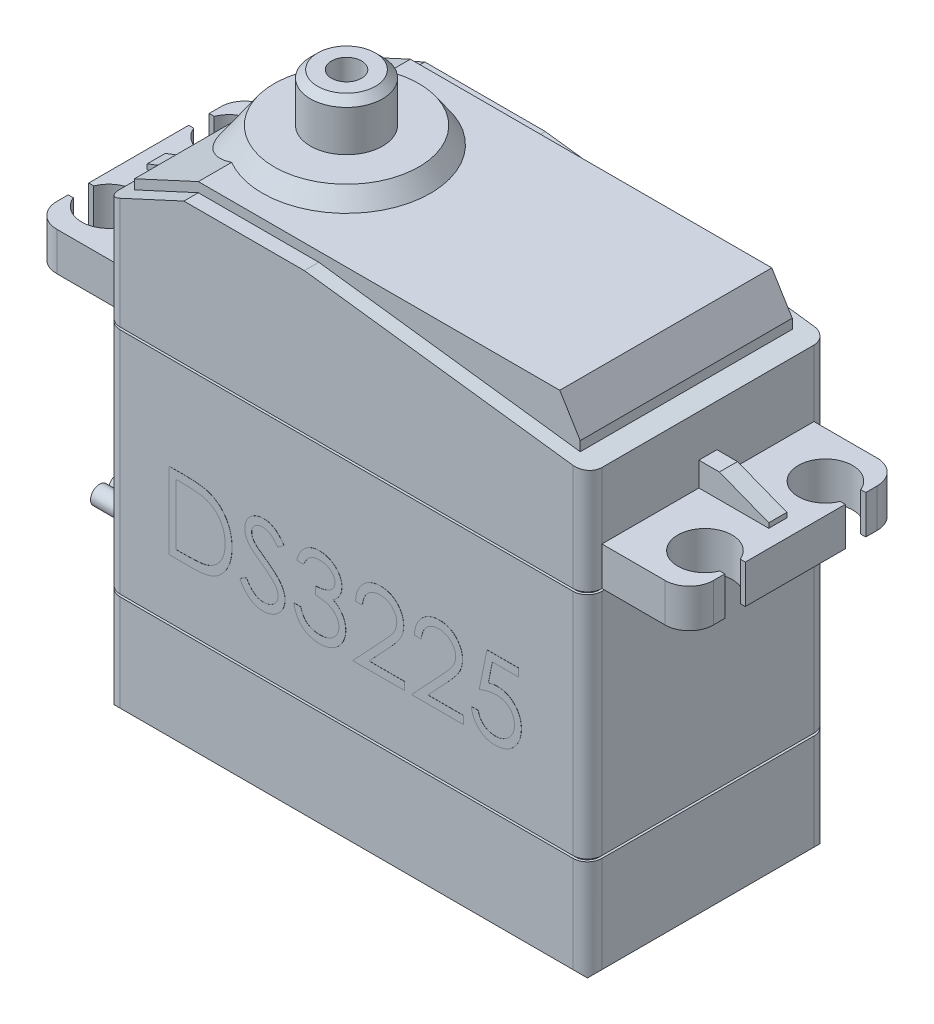
from build123d import *

# Parameters (mm, degrees)
SKETCH1_W              = 40
SKETCH1_H              = 20
BOSS_EXTRUDE1_DEPTH    = 41.5
CHAMFER1_SIZE          = 1.6
FILLET2_R              = 1.2
BOSS_EXTRUDE3_DEPTH    = 3.2
CUT_EXTRUDE1_REACH     = 55.524
BOSS_EXTRUDE4_DEPTH    = 8.8
BOSS_EXTRUDE5_REACH    = 53.797
SKETCH6_R              = 6
BOSS_EXTRUDE5_DRAFT    = 35
SKETCH7_R              = 3
SKETCH7_R_2            = 1.25
BOSS_EXTRUDE6_DEPTH    = 4
CHAMFER2_SIZE          = 0.6
BOSS_EXTRUDE7_DEPTH    = 0.75
CUT_EXTRUDE2_DEPTH     = 0.2
LPATTERN1_COUNT        = 2
LPATTERN1_PITCH        = 19.2
BOSS_EXTRUDE8_DEPTH    = 0.6
SKETCH11_W             = 6.4
SKETCH11_H             = 3.4
BOSS_EXTRUDE9_DEPTH    = 4.2
BOSS_EXTRUDE9_TAPER    = 5
FILLET3_R              = 0.5
SKETCH12_R             = 0.75
BOSS_EXTRUDE11_DEPTH   = 4.2
BOSS_EXTRUDE11_2_DEPTH = 4.2
BOSS_EXTRUDE11_3_DEPTH = 4.2
BOSS_EXTRUDE12_DEPTH   = 0.01


with BuildPart() as part:
    # Sketch1 → Boss-Extrude1 (new body)
    with BuildSketch(Plane(origin=(0, 0, 0), x_dir=(1, 0, 0), z_dir=(0, 1, 0))):
        Rectangle(SKETCH1_W, SKETCH1_H)
    extrude(amount=BOSS_EXTRUDE1_DEPTH)

    # Chamfer1
    chamfer1_edges = [part.edges().sort_by_distance(p)[0] for p in [
        (0, 0, 10),
        (-20, 0, 0),
        (0, 0, -10),
        (20, 0, 0),
    ]]
    chamfer(chamfer1_edges, length=CHAMFER1_SIZE)

    # Fillet2
    fillet2_edges = [part.edges().sort_by_distance(p)[0] for p in [
        (20, 21.55, 10),
        (-20, 21.55, 10),
        (-20, 21.55, -10),
        (20, 21.55, -10),
    ]]
    fillet(fillet2_edges, radius=FILLET2_R)

    # Sketch3 → Boss-Extrude3 (add)
    with BuildSketch(Plane(origin=(0, 29, 0), x_dir=(-1, 0, 0), z_dir=(0, -1, 0))):
        with BuildLine():
            Line((25.25, 8.8), (20, 8.8))
            Line((20, 8.8), (20, 5.85))
            Line((20, 5.85), (22.666733334, 5.85))
            ThreePointArc((22.666733334, 5.85), (24.75, 7.25), (26.833266666, 5.85))
            Line((26.833266666, 5.85), (27.25, 5.85))
            Line((27.25, 5.85), (27.25, 6.8))
            ThreePointArc((27.25, 6.8), (26.664213562, 8.214213562), (25.25, 8.8))
        make_face()
        with BuildLine():
            Line((22.666733334, 4.15), (20, 4.15))
            Line((20, 4.15), (20, -4.15))
            Line((20, -4.15), (22.666733334, -4.15))
            ThreePointArc((22.666733334, -4.15), (24.75, -2.75), (26.833266666, -4.15))
            Line((26.833266666, -4.15), (27.25, -4.15))
            Line((27.25, -4.15), (27.25, 4.15))
            Line((27.25, 4.15), (26.833266666, 4.15))
            ThreePointArc((26.833266666, 4.15), (24.75, 2.75), (22.666733334, 4.15))
        make_face()
        with BuildLine():
            Line((22.666733334, -5.85), (20, -5.85))
            Line((20, -5.85), (20, -8.8))
            Line((20, -8.8), (25.25, -8.8))
            ThreePointArc((25.25, -8.8), (26.664213562, -8.214213562), (27.25, -6.8))
            Line((27.25, -6.8), (27.25, -5.85))
            Line((27.25, -5.85), (26.833266666, -5.85))
            ThreePointArc((26.833266666, -5.85), (24.75, -7.25), (22.666733334, -5.85))
        make_face()
        with BuildLine():
            Line((22.666733334, -4.15), (20, -4.15))
            Line((20, -4.15), (20, -5.85))
            Line((20, -5.85), (22.666733334, -5.85))
            ThreePointArc((22.666733334, -5.85), (22.5, -5), (22.666733334, -4.15))
        make_face()
        with BuildLine():
            Line((22.666733334, 5.85), (20, 5.85))
            Line((20, 5.85), (20, 4.15))
            Line((20, 4.15), (22.666733334, 4.15))
            ThreePointArc((22.666733334, 4.15), (22.5, 5), (22.666733334, 5.85))
        make_face()
        with BuildLine():
            Line((-20, 5.85), (-20, 8.8))
            Line((-20, 8.8), (-25.25, 8.8))
            ThreePointArc((-25.25, 8.8), (-26.664213562, 8.214213562), (-27.25, 6.8))
            Line((-27.25, 6.8), (-27.25, 5.85))
            Line((-27.25, 5.85), (-26.833266666, 5.85))
            ThreePointArc((-26.833266666, 5.85), (-24.75, 7.25), (-22.666733334, 5.85))
            Line((-22.666733334, 5.85), (-20, 5.85))
        make_face()
        with BuildLine():
            Line((-20, 4.15), (-20, 5.85))
            Line((-20, 5.85), (-22.666733334, 5.85))
            ThreePointArc((-22.666733334, 5.85), (-22.542076768, 5.433099297), (-22.5, 5))
            ThreePointArc((-22.5, 5), (-22.542076768, 4.566900703), (-22.666733334, 4.15))
            Line((-22.666733334, 4.15), (-20, 4.15))
        make_face()
        with BuildLine():
            Line((-20, -4.15), (-20, 4.15))
            Line((-20, 4.15), (-22.666733334, 4.15))
            ThreePointArc((-22.666733334, 4.15), (-24.75, 2.75), (-26.833266666, 4.15))
            Line((-26.833266666, 4.15), (-27.25, 4.15))
            Line((-27.25, 4.15), (-27.25, -4.15))
            Line((-27.25, -4.15), (-26.833266666, -4.15))
            ThreePointArc((-26.833266666, -4.15), (-24.75, -2.75), (-22.666733334, -4.15))
            Line((-22.666733334, -4.15), (-20, -4.15))
        make_face()
        with BuildLine():
            Line((-20, -5.85), (-20, -4.15))
            Line((-20, -4.15), (-22.666733334, -4.15))
            ThreePointArc((-22.666733334, -4.15), (-22.542076768, -4.566900703), (-22.5, -5))
            ThreePointArc((-22.5, -5), (-22.542076768, -5.433099297), (-22.666733334, -5.85))
            Line((-22.666733334, -5.85), (-20, -5.85))
        make_face()
        with BuildLine():
            Line((-20, -8.8), (-20, -5.85))
            Line((-20, -5.85), (-22.666733334, -5.85))
            ThreePointArc((-22.666733334, -5.85), (-24.75, -7.25), (-26.833266666, -5.85))
            Line((-26.833266666, -5.85), (-27.25, -5.85))
            Line((-27.25, -5.85), (-27.25, -6.8))
            ThreePointArc((-27.25, -6.8), (-26.664213562, -8.214213562), (-25.25, -8.8))
            Line((-25.25, -8.8), (-20, -8.8))
        make_face()
    extrude(amount=-BOSS_EXTRUDE3_DEPTH)

    # Sketch4 → Cut-Extrude1 (cut, up to next)
    with BuildSketch(Plane.XY.offset(10), mode=Mode.PRIVATE) as cut_extrude1_sk1:
        Polygon((-20, 37.7), (-13.5, 40.7), (-3.5, 40.7), (20, 37.7), (20, 41.5), (-20, 41.5), align=None)
    cut_extrude1_tool1 = extrude(cut_extrude1_sk1.sketch, amount=-CUT_EXTRUDE1_REACH, mode=Mode.PRIVATE) & part.part
    add(cut_extrude1_tool1.solids().sort_by_distance((3.311688, 40.281818, 10))[0], mode=Mode.SUBTRACT)

    # Sketch5 → Boss-Extrude4 (add, symmetric)
    with BuildSketch(Plane.XY):
        Polygon((-13.5, 41.5), (16.5, 41.5), (18.2, 38.729787234), (18.2, 37.929787234), (-3.5, 40.7), (-13.5, 40.7), (-18.8, 38.253846154), (-18.8, 39.053846154), align=None)
    extrude(amount=BOSS_EXTRUDE4_DEPTH, both=True)




with BuildPart() as boss_extrude5_long_prism_1:
    # Sketch6 → Boss-Extrude5 (the long prism of profile 1, to be tilted and cut off)
    with BuildSketch(Plane(origin=(0, 42.9, 0), x_dir=(1, 0, 0), z_dir=(0, 1, 0))):
        with Locations((-10, 0)):
            Circle(SKETCH6_R)
    extrude(amount=-BOSS_EXTRUDE5_REACH)
    boss_extrude5_tool1_sides = [boss_extrude5_long_prism_1.faces().sort_by_distance(p)[0] for p in [
        (-16, 16.0015, 0),
    ]]
    draft(boss_extrude5_tool1_sides, Plane(origin=(0, 42.9, 0), x_dir=(1, 0, 0), z_dir=(0, 1, 0)), BOSS_EXTRUDE5_DRAFT)  # the draft: side faces tilted about the start plane


with BuildPart() as part_1:
    add(part.part)
    boss_extrude5_tool1 = boss_extrude5_long_prism_1.part - part.part
    add(boss_extrude5_tool1.solids().sort_by_distance((-10, 42.9, 0))[0])

    # Sketch7 → Boss-Extrude6 (add)
    with BuildSketch(Plane(origin=(0, 42.9, 0), x_dir=(1, 0, 0), z_dir=(0, 1, 0))):
        with Locations(Location((-10, 0, 0), (0, 0, 270))):
            Circle(SKETCH7_R)
        with Locations(Location((-10, 0, 0), (0, 0, 270))):
            Circle(SKETCH7_R_2, mode=Mode.SUBTRACT)
    extrude(amount=BOSS_EXTRUDE6_DEPTH)

    # Chamfer2
    chamfer2_edges = [part_1.edges().sort_by_distance(p)[0] for p in [
        (-10, 46.9, -3),
    ]]
    chamfer(chamfer2_edges, length=CHAMFER2_SIZE)

    # Sketch8 → Boss-Extrude7 (add, symmetric)
    with BuildSketch(Plane.XY):
        Polygon((-20, 34.2), (-21.7, 34.2), (-25.8, 32.6), (-25.8, 32.2), (-20, 32.2), align=None)
        Polygon((20, 32.2), (20, 34.2), (21.7, 34.2), (25.8, 32.6), (25.8, 32.2), align=None)
    extrude(amount=BOSS_EXTRUDE7_DEPTH, both=True)

    # Sketch9 → Cut-Extrude2 (cut)
    with BuildSketch(Plane(origin=(0, 9.6, 0), x_dir=(-1, 0, 0), z_dir=(0, -1, 0))):
        with BuildLine():
            Line((20, 8.8), (20, -8.8))
            ThreePointArc((20, -8.8), (19.908655439, -9.259220119), (19.648528137, -9.648528137))
            ThreePointArc((19.648528137, -9.648528137), (19.259220119, -9.908655439), (18.8, -10))
            Line((18.8, -10), (-18.8, -10))
            ThreePointArc((-18.8, -10), (-19.259220119, -9.908655439), (-19.648528137, -9.648528137))
            ThreePointArc((-19.648528137, -9.648528137), (-19.908655439, -9.259220119), (-20, -8.8))
            Line((-20, -8.8), (-20, 8.8))
            ThreePointArc((-20, 8.8), (-19.908655439, 9.259220119), (-19.648528137, 9.648528137))
            ThreePointArc((-19.648528137, 9.648528137), (-19.259220119, 9.908655439), (-18.8, 10))
            Line((-18.8, 10), (18.8, 10))
            ThreePointArc((18.8, 10), (19.259220119, 9.908655439), (19.648528137, 9.648528137))
            ThreePointArc((19.648528137, 9.648528137), (19.908655439, 9.259220119), (20, 8.8))
        make_face()
        with BuildLine():
            Line((-18.8, 9.8), (18.8, 9.8))
            ThreePointArc((18.8, 9.8), (19.182683432, 9.723879533), (19.507106781, 9.507106781))
            ThreePointArc((19.507106781, 9.507106781), (19.723879533, 9.182683432), (19.8, 8.8))
            Line((19.8, 8.8), (19.8, -8.8))
            ThreePointArc((19.8, -8.8), (19.723879533, -9.182683432), (19.507106781, -9.507106781))
            ThreePointArc((19.507106781, -9.507106781), (19.182683432, -9.723879533), (18.8, -9.8))
            Line((18.8, -9.8), (-18.8, -9.8))
            ThreePointArc((-18.8, -9.8), (-19.182683432, -9.723879533), (-19.507106781, -9.507106781))
            ThreePointArc((-19.507106781, -9.507106781), (-19.723879533, -9.182683432), (-19.8, -8.8))
            Line((-19.8, -8.8), (-19.8, 8.8))
            ThreePointArc((-19.8, 8.8), (-19.723879533, 9.182683432), (-19.507106781, 9.507106781))
            ThreePointArc((-19.507106781, 9.507106781), (-19.182683432, 9.723879533), (-18.8, 9.8))
        make_face(mode=Mode.SUBTRACT)
    cut_extrude2 = extrude(amount=-CUT_EXTRUDE2_DEPTH, mode=Mode.SUBTRACT)

    # LPattern1: Cut-Extrude2 ×2
    with Locations(*[(0, i * LPATTERN1_PITCH, 0) for i in range(1, LPATTERN1_COUNT)]):
        add(cut_extrude2, mode=Mode.SUBTRACT)

    # Sketch10 → Boss-Extrude8 (add)
    with BuildSketch(Plane.ZY.offset(20)):
        with BuildLine():
            Line((-3, 9.6), (3, 9.6))
            ThreePointArc((3, 9.6), (3.353553391, 9.453553391), (3.5, 9.1))
            Line((3.5, 9.1), (3.5, 6.1))
            ThreePointArc((3.5, 6.1), (3.353553391, 5.746446609), (3, 5.6))
            Line((3, 5.6), (-3, 5.6))
            ThreePointArc((-3, 5.6), (-3.353553391, 5.746446609), (-3.5, 6.1))
            Line((-3.5, 6.1), (-3.5, 9.1))
            ThreePointArc((-3.5, 9.1), (-3.353553391, 9.453553391), (-3, 9.6))
        make_face()
    extrude(amount=BOSS_EXTRUDE8_DEPTH)

    # Sketch11 → Boss-Extrude9 (add)
    with BuildSketch(Plane.ZY.offset(20.6)):
        with Locations((0, 7.6)):
            Rectangle(SKETCH11_W, SKETCH11_H)
    extrude(amount=BOSS_EXTRUDE9_DEPTH, taper=BOSS_EXTRUDE9_TAPER)

    # Fillet3
    fillet3_edges = [part_1.edges().sort_by_distance(p)[0] for p in [
        (-22.7, 6.083726193, 3.016273807),
        (-22.7, 9.116273807, 3.016273807),
        (-22.7, 9.116273807, -3.016273807),
        (-22.7, 6.083726193, -3.016273807),
        (-24.8, 7.6, 2.832547613),
        (-24.8, 8.932547613, 0),
        (-24.8, 7.6, -2.832547613),
        (-24.8, 6.267452387, 0),
    ]]
    fillet(fillet3_edges, radius=FILLET3_R)

    # Sketch13 → Boss-Extrude12 (add)
    with BuildSketch(Plane.XY.offset(10)):
        with BuildLine():
            Line((-14.705907337, 14.680709797), (-14.705907337, 21.030709797))
            Line((-14.705907337, 21.030709797), (-13.423695799, 21.030709797))
            add(Edge.make_bspline(
                [(-13.423695799, 21.030709797), (-13.312173491, 21.029906849), (-13.096712974, 21.028355556), (-12.785358963, 21.018519604), (-12.497279851, 21.001119759), (-12.233423092, 20.975775047), (-11.993064322, 20.944654543), (-11.776876561, 20.905646667), (-11.583741959, 20.859585272), (-11.464961688, 20.820314241), (-11.408791952, 20.801743451)],
                knots=[0, 0, 0, 0, 1.314313732, 2.53924729, 3.670748893, 4.714932338, 5.66265055, 6.526160246, 7.303039223, 8, 8, 8, 8], degree=3))
            add(Edge.make_bspline(
                [(-11.408791952, 20.801743451), (-11.335322925, 20.773747742), (-11.190050905, 20.718391174), (-10.983209411, 20.613967599), (-10.788490539, 20.4956524), (-10.60485009, 20.363289621), (-10.436482876, 20.213131446), (-10.276811407, 20.051556447), (-10.132367551, 19.87268903), (-10.000091071, 19.680238695), (-9.880827803, 19.476472543), (-9.777161045, 19.261778846), (-9.691065943, 19.037247911), (-9.619595374, 18.803504143), (-9.56326823, 18.560033571), (-9.524838154, 18.3065527), (-9.499490787, 18.044063314), (-9.496943436, 17.865946787), (-9.495650927, 17.775571576)],
                knots=[0, 0, 0, 0, 0.984719456, 1.947108742, 2.898477687, 3.838006223, 4.779231079, 5.722358779, 6.681677486, 7.655904652, 8.64651281, 9.637519902, 10.640069247, 11.656948941, 12.698408672, 13.768548281, 14.867775369, 16, 16, 16, 16], degree=3))
            add(Edge.make_bspline(
                [(-9.495650927, 17.775571576), (-9.496792054, 17.697083329), (-9.499040763, 17.54241404), (-9.519232522, 17.314465558), (-9.548580988, 17.093279508), (-9.594018318, 16.879909166), (-9.649177164, 16.672485114), (-9.719869267, 16.473218042), (-9.80085081, 16.280279988), (-9.895284161, 16.09627971), (-9.99895496, 15.92195702), (-10.110210123, 15.757627133), (-10.228930984, 15.605634945), (-10.356249633, 15.465520178), (-10.490520775, 15.337494057), (-10.632623489, 15.220487115), (-10.782924453, 15.116788794), (-10.940750478, 15.022324183), (-11.110705741, 14.939918681), (-11.296009384, 14.870195663), (-11.497451664, 14.812416804), (-11.714538129, 14.764209607), (-11.947643867, 14.725969358), (-12.19699742, 14.700340046), (-12.462215674, 14.683008297), (-12.644332341, 14.68149084), (-12.738068795, 14.680709797)],
                knots=[0, 0, 0, 0, 1.105936401, 2.179363191, 3.223086493, 4.248585256, 5.251745608, 6.245858792, 7.225916811, 8.198733463, 9.158002045, 10.082870192, 10.993790845, 11.873723703, 12.748670949, 13.606408763, 14.465103618, 15.319838547, 16.196477973, 17.123216899, 18.106603292, 19.147568657, 20.255746949, 21.433717677, 22.679120308, 24, 24, 24, 24], degree=3))
            Line((-12.738068795, 14.680709797), (-14.705907337, 14.680709797))
        make_face()
        with BuildLine():
            Line((-14.136035542, 15.331991848), (-13.40715934, 15.331991848))
            add(Edge.make_bspline(
                [(-13.40715934, 15.331991848), (-13.302423582, 15.332441966), (-13.100978362, 15.333307707), (-12.811313138, 15.34090449), (-12.546646233, 15.35331772), (-12.306940066, 15.370689646), (-12.092329979, 15.393674134), (-11.902367462, 15.419300743), (-11.737675207, 15.451227547), (-11.638017515, 15.480167145), (-11.591965029, 15.493540326)],
                knots=[0, 0, 0, 0, 1.375205317, 2.645023457, 3.804390687, 4.853969522, 5.800190428, 6.637939096, 7.370582563, 8, 8, 8, 8], degree=3))
            add(Edge.make_bspline(
                [(-11.591965029, 15.493540326), (-11.534001573, 15.513953867), (-11.419459115, 15.554293373), (-11.25457486, 15.627876558), (-11.100801437, 15.715038599), (-10.955458963, 15.811925582), (-10.820609174, 15.921954757), (-10.694653991, 16.042733551), (-10.577847009, 16.174876643), (-10.47139505, 16.318220022), (-10.376129984, 16.471871508), (-10.293632182, 16.634320535), (-10.221330118, 16.803787176), (-10.164581814, 16.982873793), (-10.12010354, 17.16997937), (-10.088599035, 17.365117071), (-10.068978035, 17.568250454), (-10.066689408, 17.706412165), (-10.065522722, 17.776843611)],
                knots=[0, 0, 0, 0, 0.998632004, 1.973411704, 2.929992603, 3.868527914, 4.809262121, 5.754881198, 6.702106254, 7.672490631, 8.653608572, 9.636854334, 10.631411391, 11.644891563, 12.686317036, 13.754757253, 14.855430412, 16, 16, 16, 16], degree=3))
            add(Edge.make_bspline(
                [(-10.065522722, 17.776843611), (-10.066453972, 17.85110864), (-10.06828342, 17.997002946), (-10.091278241, 18.211071778), (-10.124881634, 18.416958102), (-10.173474893, 18.614675685), (-10.235398059, 18.804610266), (-10.312676909, 18.985711378), (-10.400972061, 19.15989164), (-10.506025258, 19.323130846), (-10.621079263, 19.477514059), (-10.748764844, 19.618946548), (-10.8870534, 19.747750493), (-11.034436627, 19.865931817), (-11.195068221, 19.968735915), (-11.365164203, 20.060696037), (-11.547219921, 20.138739154), (-11.673880097, 20.180247948), (-11.738249084, 20.20134281)],
                knots=[0, 0, 0, 0, 1.122418816, 2.205001699, 3.251619955, 4.274784885, 5.280384055, 6.268708349, 7.249350384, 8.229342522, 9.199999885, 10.157847722, 11.105861043, 12.055065948, 13.010012805, 13.98527497, 14.976112212, 16, 16, 16, 16], degree=3))
            add(Edge.make_bspline(
                [(-11.738249084, 20.20134281), (-11.791500449, 20.216068329), (-11.904727463, 20.247378823), (-12.089493348, 20.281533427), (-12.297437976, 20.311658733), (-12.529484577, 20.337164033), (-12.785368638, 20.355465316), (-13.065286958, 20.369201844), (-13.369360526, 20.378466734), (-13.580148838, 20.379099388), (-13.689551167, 20.379427746)],
                knots=[0, 0, 0, 0, 0.674548936, 1.434276114, 2.292660221, 3.240891867, 4.284742987, 5.42552168, 6.663806718, 8, 8, 8, 8], degree=3))
            Line((-13.689551167, 20.379427746), (-14.136035542, 20.379427746))
            Line((-14.136035542, 20.379427746), (-14.136035542, 15.331991848))
        make_face(mode=Mode.SUBTRACT)
        with BuildLine():
            Line((-8.844368876, 15.905679749), (-8.307569997, 16.227504669))
            add(Edge.make_bspline(
                [(-8.307569997, 16.227504669), (-8.257644053, 16.143930713), (-8.161987869, 15.98380624), (-8.002418975, 15.767438081), (-7.837077836, 15.583538168), (-7.664740045, 15.433176322), (-7.486457539, 15.314796199), (-7.30106647, 15.23097215), (-7.109191585, 15.178691738), (-6.978610509, 15.172341581), (-6.913419356, 15.169171336)],
                knots=[0, 0, 0, 0, 1.272034388, 2.437168799, 3.508375237, 4.49857839, 5.41946034, 6.295179144, 7.148887113, 8, 8, 8, 8], degree=3))
            add(Edge.make_bspline(
                [(-6.913419356, 15.169171336), (-6.857744624, 15.170721956), (-6.747369335, 15.173796064), (-6.584877838, 15.20333409), (-6.427067996, 15.248713238), (-6.277192325, 15.313702643), (-6.137318853, 15.392331038), (-6.014660991, 15.48730196), (-5.908623043, 15.593630362), (-5.82188365, 15.712253178), (-5.755335586, 15.839828577), (-5.704187119, 15.970776374), (-5.675802485, 16.107153634), (-5.671526661, 16.198975473), (-5.669368876, 16.245313162)],
                knots=[0, 0, 0, 0, 1.095163259, 2.171163733, 3.241058638, 4.321873601, 5.38011039, 6.391990106, 7.366004449, 8.327778327, 9.272591725, 10.192022065, 11.087607919, 12, 12, 12, 12], degree=3))
            add(Edge.make_bspline(
                [(-5.669368876, 16.245313162), (-5.672043696, 16.29818299), (-5.677481216, 16.405659623), (-5.723439759, 16.564227565), (-5.795737678, 16.721149799), (-5.862435617, 16.818216381), (-5.897063186, 16.868610438)],
                knots=[0, 0, 0, 0, 0.938893495, 1.908633276, 2.914225137, 4, 4, 4, 4], degree=3))
            add(Edge.make_bspline(
                [(-5.897063186, 16.868610438), (-5.925494158, 16.904981104), (-5.985181426, 16.981336767), (-6.087792913, 17.094993123), (-6.208200006, 17.212229397), (-6.34228217, 17.337522258), (-6.494923631, 17.465044403), (-6.66134355, 17.60087685), (-6.845790837, 17.739853997), (-6.975148496, 17.833058509), (-7.041894917, 17.881150502)],
                knots=[0, 0, 0, 0, 0.722233717, 1.516239348, 2.393582979, 3.351407094, 4.387010283, 5.505090956, 6.712668013, 8, 8, 8, 8], degree=3))
            add(Edge.make_bspline(
                [(-7.041894917, 17.881150502), (-7.108704167, 17.928736654), (-7.236438366, 18.019717753), (-7.415070366, 18.154744668), (-7.574808177, 18.278195688), (-7.714941822, 18.391232967), (-7.835409662, 18.493871836), (-7.937160993, 18.585126669), (-8.017603804, 18.667465415), (-8.062336071, 18.72088042), (-8.082419757, 18.744862441)],
                knots=[0, 0, 0, 0, 1.452282411, 2.77665338, 3.964542531, 5.026858415, 5.96415736, 6.766646006, 7.446254459, 8, 8, 8, 8], degree=3))
            add(Edge.make_bspline(
                [(-8.082419757, 18.744862441), (-8.110491375, 18.782238608), (-8.165697979, 18.855743856), (-8.238570588, 18.970633241), (-8.300508784, 19.088241166), (-8.349063301, 19.208883663), (-8.389950441, 19.330867034), (-8.417451258, 19.455782865), (-8.434671364, 19.583070644), (-8.436434825, 19.668729424), (-8.437317594, 19.711609236)],
                knots=[0, 0, 0, 0, 1.068054152, 2.10047183, 3.106115577, 4.101338837, 5.06977816, 6.043150881, 7.020423561, 8, 8, 8, 8], degree=3))
            add(Edge.make_bspline(
                [(-8.437317594, 19.711609236), (-8.434949571, 19.778791827), (-8.430264142, 19.911721029), (-8.390639204, 20.105905535), (-8.328095525, 20.291300892), (-8.2404748, 20.46607164), (-8.127522174, 20.625667063), (-7.996810192, 20.771922961), (-7.841123638, 20.894874531), (-7.670303879, 21.002302123), (-7.483330175, 21.086386873), (-7.287403822, 21.14981608), (-7.08221342, 21.185755733), (-6.943233447, 21.190913321), (-6.872714228, 21.19353031)],
                knots=[0, 0, 0, 0, 1.005424448, 1.989358655, 2.955360095, 3.929531133, 4.905563448, 5.876582895, 6.856512386, 7.866279853, 8.892233794, 9.918561126, 10.94386622, 12, 12, 12, 12], degree=3))
            add(Edge.make_bspline(
                [(-6.872714228, 21.19353031), (-6.797885646, 21.190949395), (-6.649075479, 21.185816779), (-6.430183331, 21.141189829), (-6.219434603, 21.067347181), (-6.049901822, 20.983547759), (-5.917218098, 20.899852191), (-5.816030426, 20.823616224), (-5.713491622, 20.735849955), (-5.60877458, 20.636319609), (-5.503653669, 20.524111932), (-5.396568263, 20.399995396), (-5.287267947, 20.264728502), (-5.216953743, 20.168164051), (-5.180907337, 20.118660518)],
                knots=[0, 0, 0, 0, 1.286793592, 2.559021753, 3.825965368, 5.121522368, 5.803751409, 6.523245864, 7.299691795, 8.125521123, 9.008227632, 9.944561021, 10.946284179, 12, 12, 12, 12], degree=3))
            Line((-5.180907337, 20.118660518), (-5.696081616, 19.728145694))
            add(Edge.make_bspline(
                [(-5.696081616, 19.728145694), (-5.727189236, 19.76822089), (-5.78709524, 19.845396347), (-5.878044452, 19.953475733), (-5.963766999, 20.052202775), (-6.048222724, 20.137955221), (-6.12695117, 20.215429092), (-6.203363518, 20.281758936), (-6.276360126, 20.33759466), (-6.368375093, 20.397182261), (-6.483977239, 20.456249061), (-6.62909204, 20.506230959), (-6.780741425, 20.536266572), (-6.884028042, 20.540237839), (-6.936315991, 20.542248259)],
                knots=[0, 0, 0, 0, 1.181633172, 2.275549214, 3.290209073, 4.226197932, 5.078386478, 5.862611352, 6.581680152, 7.217281963, 8.414376989, 9.595101626, 10.782541182, 12, 12, 12, 12], degree=3))
            add(Edge.make_bspline(
                [(-6.936315991, 20.542248259), (-7.001914253, 20.540049889), (-7.128414322, 20.535810539), (-7.308010893, 20.489509995), (-7.469652729, 20.41660862), (-7.608540954, 20.314437159), (-7.724178041, 20.193386215), (-7.807826516, 20.054087435), (-7.858173243, 19.900267934), (-7.864316922, 19.792968071), (-7.867445799, 19.738321977)],
                knots=[0, 0, 0, 0, 1.14458467, 2.207223713, 3.21896685, 4.227309161, 5.202851033, 6.127160689, 7.046193047, 8, 8, 8, 8], degree=3))
            add(Edge.make_bspline(
                [(-7.867445799, 19.738321977), (-7.866732555, 19.704301437), (-7.8653049, 19.636204727), (-7.845393482, 19.535600005), (-7.81981327, 19.435249432), (-7.779277353, 19.335604174), (-7.723315159, 19.234921551), (-7.649827197, 19.131467828), (-7.557274474, 19.024331156), (-7.486377609, 18.954649207), (-7.448946199, 18.917859236)],
                knots=[0, 0, 0, 0, 0.858281714, 1.717966888, 2.583508476, 3.4729293, 4.427298488, 5.488583878, 6.674047936, 8, 8, 8, 8], degree=3))
            add(Edge.make_bspline(
                [(-7.448946199, 18.917859236), (-7.435046281, 18.905454918), (-7.402023256, 18.875985097), (-7.341651219, 18.827739102), (-7.261926428, 18.768225501), (-7.16493072, 18.694588513), (-7.04887565, 18.609169288), (-6.913748455, 18.513060021), (-6.761055389, 18.403140688), (-6.65270277, 18.326292007), (-6.595410542, 18.285657714)],
                knots=[0, 0, 0, 0, 0.420754252, 0.999615792, 1.744751191, 2.668019286, 3.750313428, 4.999500688, 6.413464383, 8, 8, 8, 8], degree=3))
            add(Edge.make_bspline(
                [(-6.595410542, 18.285657714), (-6.526493242, 18.23550839), (-6.393044443, 18.138401175), (-6.203165691, 17.992504156), (-6.03100121, 17.849814633), (-5.875946541, 17.711243831), (-5.736469864, 17.577842862), (-5.614118571, 17.448006807), (-5.50764598, 17.322665839), (-5.393020826, 17.16196988), (-5.275894496, 16.964609913), (-5.175307762, 16.722805109), (-5.111883331, 16.480060356), (-5.103589296, 16.316907381), (-5.099497081, 16.236408916)],
                knots=[0, 0, 0, 0, 1.163667725, 2.253281268, 3.268753668, 4.215851969, 5.092017293, 5.902905408, 6.650798638, 7.335211899, 8.59617414, 9.77448103, 10.901945474, 12, 12, 12, 12], degree=3))
            add(Edge.make_bspline(
                [(-5.099497081, 16.236408916), (-5.100689317, 16.179479596), (-5.103050637, 16.066726486), (-5.130194009, 15.901163704), (-5.169962545, 15.740361983), (-5.229901526, 15.586308965), (-5.303059256, 15.436186324), (-5.395889449, 15.29393199), (-5.503490534, 15.156397524), (-5.626923222, 15.027250333), (-5.761989359, 14.908693663), (-5.904744062, 14.803230937), (-6.055420986, 14.71529555), (-6.213202732, 14.643539023), (-6.378125543, 14.587416784), (-6.55013395, 14.546753435), (-6.729511492, 14.521796646), (-6.851432366, 14.519206278), (-6.913419356, 14.517889284)],
                knots=[0, 0, 0, 0, 0.983748083, 1.948392443, 2.894712957, 3.844097841, 4.80183111, 5.778335162, 6.776009319, 7.81870978, 8.863265674, 9.881300176, 10.883814829, 11.87499822, 12.874611388, 13.892143829, 14.928324115, 16, 16, 16, 16], degree=3))
            add(Edge.make_bspline(
                [(-6.913419356, 14.517889284), (-6.961380621, 14.518816714), (-7.056699129, 14.520659893), (-7.197686332, 14.536954501), (-7.335825301, 14.560008818), (-7.469382641, 14.596610345), (-7.600079088, 14.641018575), (-7.727346213, 14.695698121), (-7.851245697, 14.761225044), (-7.972471883, 14.836146017), (-8.090716457, 14.923336496), (-8.204870349, 15.024888411), (-8.318679014, 15.13800097), (-8.42878329, 15.265745849), (-8.53741028, 15.406059228), (-8.642418252, 15.56025389), (-8.745980797, 15.727489946), (-8.810960288, 15.845173744), (-8.844368876, 15.905679749)],
                knots=[0, 0, 0, 0, 0.915332311, 1.819136955, 2.706846663, 3.586547465, 4.459518054, 5.340707479, 6.227863349, 7.133153174, 8.059268498, 9.028702269, 10.047606654, 11.120612155, 12.245963614, 13.433783089, 14.680604001, 16, 16, 16, 16], degree=3))
        make_face()
        with BuildLine():
            Line((-3.552702209, 19.565325182), (-4.122574004, 19.565325182))
            add(Edge.make_bspline(
                [(-4.122574004, 19.565325182), (-4.107135248, 19.629246974), (-4.076953742, 19.75420885), (-4.01400243, 19.932747737), (-3.945423781, 20.101700412), (-3.863074977, 20.257903288), (-3.773251952, 20.404495583), (-3.670340728, 20.538152423), (-3.559089232, 20.662273089), (-3.436035395, 20.772424249), (-3.306987681, 20.872169558), (-3.170127728, 20.957214304), (-3.028209049, 21.030373839), (-2.880248365, 21.090644831), (-2.725805168, 21.136048281), (-2.566275708, 21.168989914), (-2.401241929, 21.190382364), (-2.289214158, 21.192470177), (-2.232329613, 21.19353031)],
                knots=[0, 0, 0, 0, 1.162005537, 2.271625781, 3.343758855, 4.383309926, 5.390229558, 6.379919256, 7.361854164, 8.333198761, 9.295911338, 10.242430842, 11.177959212, 12.116337295, 13.062827104, 14.020064771, 14.994644689, 16, 16, 16, 16], degree=3))
            add(Edge.make_bspline(
                [(-2.232329613, 21.19353031), (-2.149448066, 21.191027992), (-1.985492861, 21.186077939), (-1.744622761, 21.140876033), (-1.512345532, 21.069347579), (-1.291203611, 20.970516674), (-1.085793027, 20.848619691), (-0.903028802, 20.703540812), (-0.745388218, 20.538079222), (-0.61313699, 20.355321569), (-0.509586635, 20.160003717), (-0.433229928, 19.958980574), (-0.386744879, 19.752728998), (-0.38072044, 19.613469363), (-0.377702209, 19.543700582)],
                knots=[0, 0, 0, 0, 1.083050992, 2.142477498, 3.193116406, 4.255571735, 5.30263384, 6.308962982, 7.297363603, 8.282367274, 9.249857812, 10.179914175, 11.08814088, 12, 12, 12, 12], degree=3))
            add(Edge.make_bspline(
                [(-0.377702209, 19.543700582), (-0.379813296, 19.476559683), (-0.383944364, 19.345175363), (-0.41902123, 19.153366361), (-0.478051307, 18.972588029), (-0.559820734, 18.802079349), (-0.665668975, 18.642921426), (-0.793889439, 18.494756167), (-0.945387125, 18.356926408), (-1.060193199, 18.27796965), (-1.119298763, 18.237320374)],
                knots=[0, 0, 0, 0, 1.024540389, 2.004866551, 2.965041327, 3.920577974, 4.882998113, 5.874504559, 6.905732034, 8, 8, 8, 8], degree=3))
            add(Edge.make_bspline(
                [(-1.119298763, 18.237320374), (-1.051749723, 18.204702834), (-0.917915537, 18.140078054), (-0.735488147, 18.013339751), (-0.569884002, 17.867006092), (-0.477530112, 17.752810136), (-0.43112769, 17.695433355)],
                knots=[0, 0, 0, 0, 1.015518401, 2.012035669, 3.001164323, 4, 4, 4, 4], degree=3))
            add(Edge.make_bspline(
                [(-0.43112769, 17.695433355), (-0.400572683, 17.653600005), (-0.339963029, 17.570618357), (-0.265149989, 17.43720227), (-0.197279167, 17.302307425), (-0.144392341, 17.162318217), (-0.103436896, 17.018857178), (-0.074161524, 16.871677973), (-0.055974868, 16.720660419), (-0.053370367, 16.61849349), (-0.052061183, 16.567138082)],
                knots=[0, 0, 0, 0, 1.025084078, 2.033381695, 3.024893161, 4.013698104, 4.991890475, 5.976764909, 6.982997093, 8, 8, 8, 8], degree=3))
            add(Edge.make_bspline(
                [(-0.052061183, 16.567138082), (-0.055316944, 16.478220445), (-0.061813142, 16.300803619), (-0.119877677, 16.038685196), (-0.209890271, 15.782461784), (-0.337719283, 15.537397433), (-0.493507478, 15.308107313), (-0.678850052, 15.102954581), (-0.891641107, 14.926608542), (-1.128959927, 14.779269985), (-1.386075289, 14.661490326), (-1.66107672, 14.579743252), (-1.950001818, 14.526501224), (-2.148135058, 14.520791904), (-2.248866071, 14.517889284)],
                knots=[0, 0, 0, 0, 0.955779014, 1.907060117, 2.875433937, 3.871313158, 4.872415639, 5.851225146, 6.836215519, 7.83643374, 8.849228613, 9.86973379, 10.916971861, 12, 12, 12, 12], degree=3))
            add(Edge.make_bspline(
                [(-2.248866071, 14.517889284), (-2.316755373, 14.519464471), (-2.450338881, 14.522563914), (-2.646723514, 14.543752233), (-2.834178597, 14.582450957), (-3.012957581, 14.634526954), (-3.18321929, 14.700551971), (-3.344444167, 14.782773038), (-3.497624116, 14.879495334), (-3.641313642, 14.991860558), (-3.775495615, 15.117556703), (-3.896604129, 15.258815193), (-4.006658325, 15.413024768), (-4.102711398, 15.581976599), (-4.18913844, 15.76348728), (-4.26022389, 15.959880984), (-4.322790565, 16.169401995), (-4.35187985, 16.31541161), (-4.366804773, 16.390325182)],
                knots=[0, 0, 0, 0, 1.048658725, 2.063410685, 3.046034179, 4.001477787, 4.936774919, 5.862367409, 6.792675028, 7.730719943, 8.675894397, 9.627829632, 10.600096036, 11.597688215, 12.626045268, 13.701542398, 14.82072376, 16, 16, 16, 16], degree=3))
            Line((-4.366804773, 16.390325182), (-3.796932978, 16.390325182))
            add(Edge.make_bspline(
                [(-3.796932978, 16.390325182), (-3.782086149, 16.341431972), (-3.753207778, 16.246330432), (-3.70405098, 16.109460163), (-3.648047115, 15.983987695), (-3.587967844, 15.868992602), (-3.524869806, 15.763342386), (-3.454267014, 15.66983071), (-3.381388708, 15.584350271), (-3.326453309, 15.536190761), (-3.299567193, 15.512620855)],
                knots=[0, 0, 0, 0, 1.198163088, 2.33053128, 3.407730985, 4.417276592, 5.372219308, 6.28897303, 7.162600585, 8, 8, 8, 8], degree=3))
            add(Edge.make_bspline(
                [(-3.299567193, 15.512620855), (-3.264013404, 15.48521002), (-3.193015573, 15.430472963), (-3.077321782, 15.360620008), (-2.955646917, 15.300093576), (-2.82535458, 15.253858871), (-2.689256353, 15.21471083), (-2.545152419, 15.189092173), (-2.394314125, 15.171515063), (-2.291321183, 15.169963973), (-2.238689789, 15.169171336)],
                knots=[0, 0, 0, 0, 0.946170439, 1.889420265, 2.845303464, 3.807233317, 4.801018734, 5.828864929, 6.890507805, 8, 8, 8, 8], degree=3))
            add(Edge.make_bspline(
                [(-2.238689789, 15.169171336), (-2.179265577, 15.170288764), (-2.063066661, 15.172473798), (-1.893512844, 15.192568294), (-1.732209332, 15.221833473), (-1.580947024, 15.267032742), (-1.437744532, 15.322878001), (-1.304609254, 15.392997251), (-1.179793461, 15.475265532), (-1.064895825, 15.568772291), (-0.961580405, 15.671137003), (-0.870613002, 15.778203575), (-0.793279688, 15.88952058), (-0.730898053, 16.005704028), (-0.681639197, 16.126272801), (-0.648105391, 16.251565248), (-0.62478907, 16.380556002), (-0.622890217, 16.46823856), (-0.621932978, 16.512440566)],
                knots=[0, 0, 0, 0, 1.217147791, 2.380027433, 3.494444702, 4.572153297, 5.609568379, 6.639424714, 7.649109417, 8.668170816, 9.669597737, 10.625200337, 11.543417969, 12.441394052, 13.322311151, 14.205496177, 15.095365482, 16, 16, 16, 16], degree=3))
            add(Edge.make_bspline(
                [(-0.621932978, 16.512440566), (-0.624709382, 16.571606853), (-0.630248376, 16.689645022), (-0.672536798, 16.863304049), (-0.742094452, 17.030623669), (-0.839471723, 17.188749174), (-0.958009402, 17.335299738), (-1.096557161, 17.466057999), (-1.256265518, 17.573953736), (-1.403258709, 17.648500298), (-1.533461208, 17.699367563), (-1.644886262, 17.733249284), (-1.769630386, 17.761939774), (-1.906185047, 17.788632038), (-2.055579168, 17.811349341), (-2.217650106, 17.830293778), (-2.392430702, 17.84545221), (-2.513427531, 17.852221483), (-2.575779132, 17.855709797)],
                knots=[0, 0, 0, 0, 1.07054697, 2.135767047, 3.216561865, 4.33974944, 5.486079747, 6.621378074, 7.775625952, 8.963672916, 9.598146892, 10.304877434, 11.070270905, 11.915000392, 12.823868403, 13.805723172, 14.86925407, 16, 16, 16, 16], degree=3))
            Line((-2.575779132, 17.855709797), (-2.575779132, 18.506991848))
            add(Edge.make_bspline(
                [(-2.575779132, 18.506991848), (-2.497218446, 18.508324992), (-2.34333736, 18.510936294), (-2.118557693, 18.542519398), (-1.903613255, 18.586208538), (-1.703267594, 18.653128815), (-1.520662071, 18.730853354), (-1.362239365, 18.821299505), (-1.230218969, 18.921837693), (-1.125242454, 19.034019713), (-1.046267996, 19.154334156), (-0.988525092, 19.279731521), (-0.954415929, 19.411310889), (-0.949862676, 19.501108358), (-0.947574004, 19.546244653)],
                knots=[0, 0, 0, 0, 1.321986639, 2.589447074, 3.816329219, 5.01088745, 6.139805852, 7.153945165, 8.075214402, 8.924034688, 9.728124013, 10.488707548, 11.240355623, 12, 12, 12, 12], degree=3))
            add(Edge.make_bspline(
                [(-0.947574004, 19.546244653), (-0.948325864, 19.579405705), (-0.949821653, 19.645378045), (-0.968685286, 19.741762098), (-0.99703176, 19.835199528), (-1.036002126, 19.925292984), (-1.088163201, 20.011417624), (-1.150585491, 20.09430771), (-1.22491333, 20.173489995), (-1.310085784, 20.247295717), (-1.401547201, 20.31763419), (-1.501786079, 20.377348932), (-1.607780052, 20.428412116), (-1.719646468, 20.470520784), (-1.837748359, 20.502196921), (-1.961530828, 20.524940519), (-2.091229911, 20.539160264), (-2.179715767, 20.541207533), (-2.224697401, 20.542248259)],
                knots=[0, 0, 0, 0, 0.884392785, 1.759457502, 2.611959086, 3.489218968, 4.37281399, 5.2945488, 6.255912374, 7.266815255, 8.301784654, 9.332968512, 10.37626691, 11.440494194, 12.520033166, 13.637162961, 14.798855837, 16, 16, 16, 16], degree=3))
            add(Edge.make_bspline(
                [(-2.224697401, 20.542248259), (-2.296999713, 20.53972393), (-2.438222945, 20.53479333), (-2.641812865, 20.491607863), (-2.831077943, 20.422704769), (-2.975746666, 20.340457719), (-3.082576479, 20.259267646), (-3.158916067, 20.188361031), (-3.233883279, 20.10956148), (-3.30254615, 20.01801557), (-3.371986079, 19.919922965), (-3.435204069, 19.810297143), (-3.496635225, 19.691997742), (-3.53365128, 19.60836709), (-3.552702209, 19.565325182)],
                knots=[0, 0, 0, 0, 1.472543308, 2.876219568, 4.221790263, 5.565193594, 6.249813518, 6.953379497, 7.687249741, 8.463570142, 9.283606569, 10.136032583, 11.040678096, 12, 12, 12, 12], degree=3))
        make_face()
        with BuildLine():
            Line((1.331913176, 19.076863643), (0.762041381, 19.076863643))
            add(Edge.make_bspline(
                [(0.762041381, 19.076863643), (0.765755501, 19.15246654), (0.773049935, 19.300948616), (0.807209831, 19.517436275), (0.85608828, 19.724364267), (0.925197061, 19.920071111), (1.011024165, 20.106287232), (1.113948643, 20.282272975), (1.235857486, 20.447356989), (1.374118275, 20.60000889), (1.524284234, 20.740049197), (1.686310725, 20.860980852), (1.856572417, 20.963157199), (2.034552755, 21.048576023), (2.222259777, 21.112692601), (2.417990105, 21.160266147), (2.622603681, 21.188888946), (2.762013436, 21.191965585), (2.832914778, 21.19353031)],
                knots=[0, 0, 0, 0, 1.10065271, 2.161652631, 3.183658789, 4.190468796, 5.17591951, 6.163126047, 7.15150782, 8.156236427, 9.156009102, 10.134482811, 11.092018607, 12.041330605, 13.001268258, 13.972401359, 14.968799086, 16, 16, 16, 16], degree=3))
            add(Edge.make_bspline(
                [(2.832914778, 21.19353031), (2.90254357, 21.191900253), (3.039361658, 21.18869725), (3.239045598, 21.161190811), (3.429141547, 21.118109524), (3.609277923, 21.05766584), (3.778017498, 20.976414093), (3.936627879, 20.878809987), (4.08699735, 20.765925436), (4.222355371, 20.633022088), (4.346648601, 20.49114062), (4.453876978, 20.339669709), (4.545703717, 20.183225147), (4.622244222, 20.020613982), (4.678588932, 19.850305116), (4.721366538, 19.674778048), (4.745546274, 19.492215891), (4.749257256, 19.36865114), (4.751143945, 19.305829989)],
                knots=[0, 0, 0, 0, 1.111607364, 2.184268762, 3.212621178, 4.221274766, 5.211760367, 6.196651075, 7.1921475, 8.207485113, 9.220403448, 10.201281604, 11.166441695, 12.114753415, 13.065576456, 14.026450734, 14.996634279, 16, 16, 16, 16], degree=3))
            add(Edge.make_bspline(
                [(4.751143945, 19.305829989), (4.748071882, 19.217387489), (4.741981667, 19.04205453), (4.689885584, 18.784398994), (4.6085212, 18.534765219), (4.510554567, 18.333856114), (4.41172599, 18.171961061), (4.322667226, 18.038667839), (4.21840964, 17.895147918), (4.097435794, 17.741881892), (3.962248154, 17.577669249), (3.811622229, 17.402609192), (3.644483912, 17.21851041), (3.527174918, 17.092770247), (3.466388336, 17.027614845)],
                knots=[0, 0, 0, 0, 1.184426356, 2.348067706, 3.509069118, 4.696110526, 5.333549288, 6.050745305, 6.844228056, 7.710549037, 8.667450064, 9.695053472, 10.805634456, 12, 12, 12, 12], degree=3))
            Line((3.466388336, 17.027614845), (1.877616301, 15.331991848))
            Line((1.877616301, 15.331991848), (4.832554201, 15.331991848))
            Line((4.832554201, 15.331991848), (4.832554201, 14.680709797))
            Line((4.832554201, 14.680709797), (0.517810612, 14.680709797))
            Line((0.517810612, 14.680709797), (2.980470868, 17.308734637))
            add(Edge.make_bspline(
                [(2.980470868, 17.308734637), (3.040429177, 17.371324422), (3.155596818, 17.491546589), (3.318488064, 17.667065959), (3.464790229, 17.829897269), (3.595450355, 17.979732864), (3.707634001, 18.118764423), (3.807187907, 18.242489099), (3.886954051, 18.356343602), (3.973523412, 18.488315858), (4.057368778, 18.649446777), (4.129418338, 18.846357899), (4.173350992, 19.049063057), (4.178621193, 19.186045324), (4.18127215, 19.254948579)],
                knots=[0, 0, 0, 0, 1.329631726, 2.553950428, 3.673215718, 4.687767853, 5.603093632, 6.413772471, 7.123043292, 7.734684054, 8.834405432, 9.900288307, 10.943827018, 12, 12, 12, 12], degree=3))
            add(Edge.make_bspline(
                [(4.18127215, 19.254948579), (4.180118732, 19.298276259), (4.177845566, 19.383666796), (4.157783744, 19.508862959), (4.127466111, 19.62963055), (4.084022571, 19.746341044), (4.026678914, 19.857821013), (3.956877211, 19.964206156), (3.876340953, 20.067056136), (3.783175079, 20.163491405), (3.680828464, 20.251813021), (3.572707468, 20.330052433), (3.458316565, 20.395437677), (3.338138058, 20.449038021), (3.212506992, 20.491084784), (3.081180383, 20.520219636), (2.944521096, 20.538512142), (2.85120604, 20.54098714), (2.803657967, 20.542248259)],
                knots=[0, 0, 0, 0, 0.991446411, 1.95395049, 2.89581595, 3.838931463, 4.798493298, 5.75982156, 6.748411868, 7.785213223, 8.824556874, 9.840280684, 10.836137867, 11.835679398, 12.848801643, 13.863922112, 14.911575587, 16, 16, 16, 16], degree=3))
            add(Edge.make_bspline(
                [(2.803657967, 20.542248259), (2.753999457, 20.540950986), (2.656478341, 20.538403356), (2.513296666, 20.520582237), (2.376706756, 20.489837641), (2.246365018, 20.447788532), (2.122050912, 20.394342308), (2.004369003, 20.327772999), (1.893583476, 20.248337233), (1.789486069, 20.158275081), (1.693575707, 20.058003862), (1.609307804, 19.946225786), (1.535676807, 19.824981761), (1.47143434, 19.694598933), (1.419263303, 19.553894218), (1.37939773, 19.403367097), (1.347853022, 19.243671162), (1.337314706, 19.133389651), (1.331913176, 19.076863643)],
                knots=[0, 0, 0, 0, 1.031018746, 2.02475058, 2.990194455, 3.934040569, 4.864654155, 5.795059489, 6.735614925, 7.690564532, 8.649604399, 9.611025574, 10.590972636, 11.591080095, 12.624614302, 13.701020113, 14.821632451, 16, 16, 16, 16], degree=3))
        make_face()
        with BuildLine():
            Line((6.21652856, 19.076863643), (5.646656765, 19.076863643))
            add(Edge.make_bspline(
                [(5.646656765, 19.076863643), (5.650370886, 19.15246654), (5.65766532, 19.300948616), (5.691825216, 19.517436275), (5.740703665, 19.724364267), (5.809812445, 19.920071111), (5.895639549, 20.106287232), (5.998564028, 20.282272975), (6.120472871, 20.447356989), (6.25873366, 20.60000889), (6.408899619, 20.740049197), (6.570926109, 20.860980852), (6.741187802, 20.963157199), (6.91916814, 21.048576023), (7.106875162, 21.112692601), (7.30260549, 21.160266147), (7.507219066, 21.188888946), (7.64662882, 21.191965585), (7.717530163, 21.19353031)],
                knots=[0, 0, 0, 0, 1.10065271, 2.161652631, 3.183658789, 4.190468796, 5.17591951, 6.163126047, 7.15150782, 8.156236427, 9.156009102, 10.134482811, 11.092018607, 12.041330605, 13.001268258, 13.972401359, 14.968799086, 16, 16, 16, 16], degree=3))
            add(Edge.make_bspline(
                [(7.717530163, 21.19353031), (7.787158954, 21.191900253), (7.923977043, 21.18869725), (8.123660983, 21.161190811), (8.313756932, 21.118109524), (8.493893308, 21.05766584), (8.662632882, 20.976414093), (8.821243263, 20.878809987), (8.971612734, 20.765925436), (9.106970756, 20.633022088), (9.231263985, 20.49114062), (9.338492363, 20.339669709), (9.430319102, 20.183225147), (9.506859607, 20.020613982), (9.563204316, 19.850305116), (9.605981922, 19.674778048), (9.630161658, 19.492215891), (9.633872641, 19.36865114), (9.63575933, 19.305829989)],
                knots=[0, 0, 0, 0, 1.111607364, 2.184268762, 3.212621178, 4.221274766, 5.211760367, 6.196651075, 7.1921475, 8.207485113, 9.220403448, 10.201281604, 11.166441695, 12.114753415, 13.065576456, 14.026450734, 14.996634279, 16, 16, 16, 16], degree=3))
            add(Edge.make_bspline(
                [(9.63575933, 19.305829989), (9.632687267, 19.217387489), (9.626597052, 19.04205453), (9.574500969, 18.784398994), (9.493136584, 18.534765219), (9.395169951, 18.333856114), (9.296341374, 18.171961061), (9.20728261, 18.038667839), (9.103025025, 17.895147918), (8.982051178, 17.741881892), (8.846863539, 17.577669249), (8.696237614, 17.402609192), (8.529099297, 17.21851041), (8.411790302, 17.092770247), (8.351003721, 17.027614845)],
                knots=[0, 0, 0, 0, 1.184426356, 2.348067706, 3.509069118, 4.696110526, 5.333549288, 6.050745305, 6.844228056, 7.710549037, 8.667450064, 9.695053472, 10.805634456, 12, 12, 12, 12], degree=3))
            Line((8.351003721, 17.027614845), (6.762231685, 15.331991848))
            Line((6.762231685, 15.331991848), (9.717169586, 15.331991848))
            Line((9.717169586, 15.331991848), (9.717169586, 14.680709797))
            Line((9.717169586, 14.680709797), (5.402425996, 14.680709797))
            Line((5.402425996, 14.680709797), (7.865086253, 17.308734637))
            add(Edge.make_bspline(
                [(7.865086253, 17.308734637), (7.925044562, 17.371324422), (8.040212202, 17.491546589), (8.203103449, 17.667065959), (8.349405613, 17.829897269), (8.48006574, 17.979732864), (8.592249386, 18.118764423), (8.691803292, 18.242489099), (8.771569436, 18.356343602), (8.858138796, 18.488315858), (8.941984163, 18.649446777), (9.014033723, 18.846357899), (9.057966377, 19.049063057), (9.063236578, 19.186045324), (9.065887535, 19.254948579)],
                knots=[0, 0, 0, 0, 1.329631726, 2.553950428, 3.673215718, 4.687767853, 5.603093632, 6.413772471, 7.123043292, 7.734684054, 8.834405432, 9.900288307, 10.943827018, 12, 12, 12, 12], degree=3))
            add(Edge.make_bspline(
                [(9.065887535, 19.254948579), (9.064734117, 19.298276259), (9.062460951, 19.383666796), (9.042399128, 19.508862959), (9.012081496, 19.62963055), (8.968637956, 19.746341044), (8.911294299, 19.857821013), (8.841492596, 19.964206156), (8.760956338, 20.067056136), (8.667790463, 20.163491405), (8.565443849, 20.251813021), (8.457322853, 20.330052433), (8.34293195, 20.395437677), (8.222753442, 20.449038021), (8.097122376, 20.491084784), (7.965795767, 20.520219636), (7.829136481, 20.538512142), (7.735821424, 20.54098714), (7.688273352, 20.542248259)],
                knots=[0, 0, 0, 0, 0.991446411, 1.95395049, 2.89581595, 3.838931463, 4.798493298, 5.75982156, 6.748411868, 7.785213223, 8.824556874, 9.840280684, 10.836137867, 11.835679398, 12.848801643, 13.863922112, 14.911575587, 16, 16, 16, 16], degree=3))
            add(Edge.make_bspline(
                [(7.688273352, 20.542248259), (7.638614841, 20.540950986), (7.541093725, 20.538403356), (7.397912051, 20.520582237), (7.26132214, 20.489837641), (7.130980402, 20.447788532), (7.006666297, 20.394342308), (6.888984388, 20.327772999), (6.77819886, 20.248337233), (6.674101454, 20.158275081), (6.578191092, 20.058003862), (6.493923188, 19.946225786), (6.420292191, 19.824981761), (6.356049725, 19.694598933), (6.303878687, 19.553894218), (6.264013114, 19.403367097), (6.232468407, 19.243671162), (6.221930091, 19.133389651), (6.21652856, 19.076863643)],
                knots=[0, 0, 0, 0, 1.031018746, 2.02475058, 2.990194455, 3.934040569, 4.864654155, 5.795059489, 6.735614925, 7.690564532, 8.649604399, 9.611025574, 10.590972636, 11.591080095, 12.624614302, 13.701020113, 14.821632451, 16, 16, 16, 16], degree=3))
        make_face()
        with BuildLine():
            Line((14.276143945, 21.030709797), (14.276143945, 20.379427746))
            Line((14.276143945, 20.379427746), (12.11622808, 20.379427746))
            Line((12.11622808, 20.379427746), (11.774050596, 18.709245454))
            add(Edge.make_bspline(
                [(11.774050596, 18.709245454), (11.841280539, 18.72780609), (11.971527922, 18.763764387), (12.163769384, 18.803689142), (12.346272381, 18.827756447), (12.464700553, 18.831042682), (12.522007326, 18.832632874)],
                knots=[0, 0, 0, 0, 1.100273476, 2.13160584, 3.095893838, 4, 4, 4, 4], degree=3))
            add(Edge.make_bspline(
                [(12.522007326, 18.832632874), (12.592916397, 18.831098105), (12.732341346, 18.828080366), (12.936337722, 18.799102867), (13.131070256, 18.753491879), (13.3161317, 18.689773218), (13.491864413, 18.608294131), (13.65665156, 18.506512811), (13.812966631, 18.387616624), (13.958005337, 18.250919245), (14.089585153, 18.100475741), (14.205274877, 17.938717889), (14.303541291, 17.767217702), (14.382572946, 17.584336597), (14.445681667, 17.392096419), (14.487686001, 17.188474448), (14.515656316, 16.975390002), (14.518781216, 16.829694567), (14.520374714, 16.7553993)],
                knots=[0, 0, 0, 0, 1.052922333, 2.070308379, 3.05430497, 4.020497103, 4.973039431, 5.925935799, 6.892292201, 7.88610001, 8.88166317, 9.857072816, 10.836096531, 11.812156883, 12.81219415, 13.836441305, 14.89672472, 16, 16, 16, 16], degree=3))
            add(Edge.make_bspline(
                [(14.520374714, 16.7553993), (14.519168078, 16.703651843), (14.516771111, 16.600856252), (14.504581674, 16.44819463), (14.481112589, 16.298764919), (14.449602575, 16.152547294), (14.408704188, 16.009818576), (14.359194047, 15.870170232), (14.298604112, 15.734471446), (14.232144331, 15.601438229), (14.157311435, 15.47407808), (14.074256143, 15.354972062), (13.986507323, 15.242333437), (13.892089381, 15.137370235), (13.790124719, 15.040772189), (13.681848207, 14.951966021), (13.568123846, 14.869449893), (13.447192192, 14.79657331), (13.321747973, 14.729511947), (13.189979636, 14.674496386), (13.054886651, 14.625310143), (12.914524662, 14.586104285), (12.769211602, 14.555383794), (12.618707938, 14.534518418), (12.463803008, 14.519321167), (12.3588012, 14.518369834), (12.305761333, 14.517889284)],
                knots=[0, 0, 0, 0, 1.056347294, 2.098418968, 3.122841568, 4.141288669, 5.149314143, 6.15115421, 7.162517403, 8.180376062, 9.185164535, 10.17417709, 11.141909838, 12.097768115, 13.052685741, 14.0056014, 14.954263652, 15.917497458, 16.885230207, 17.854509472, 18.828990115, 19.81800267, 20.826176721, 21.857883937, 22.917946725, 24, 24, 24, 24], degree=3))
            add(Edge.make_bspline(
                [(12.305761333, 14.517889284), (12.242489605, 14.519142662), (12.118009955, 14.521608534), (11.935636926, 14.547404929), (11.760168999, 14.584350891), (11.593018672, 14.639933838), (11.432687951, 14.709579358), (11.281335306, 14.797601555), (11.135093398, 14.897349358), (10.999907274, 15.015060855), (10.874438325, 15.143722164), (10.762122231, 15.283345313), (10.66209417, 15.431625872), (10.575955972, 15.589283952), (10.50248099, 15.755905286), (10.444759512, 15.932114159), (10.398171639, 16.116989881), (10.37846229, 16.244268393), (10.368451637, 16.308914925)],
                knots=[0, 0, 0, 0, 1.0467383, 2.05933395, 3.04377827, 4.011590433, 4.970194871, 5.932262533, 6.905835911, 7.896367577, 8.894135286, 9.877477877, 10.858688626, 11.851381753, 12.8477658, 13.868841284, 14.917554742, 16, 16, 16, 16], degree=3))
            Line((10.368451637, 16.308914925), (10.938323432, 16.308914925))
            add(Edge.make_bspline(
                [(10.938323432, 16.308914925), (10.952345243, 16.248360504), (10.979295943, 16.131971545), (11.038452087, 15.96844754), (11.110780176, 15.82272552), (11.196785208, 15.692877848), (11.29938312, 15.579650095), (11.416457941, 15.478744854), (11.547717382, 15.387712834), (11.69357367, 15.311834385), (11.847448828, 15.247121075), (12.008497909, 15.204028714), (12.172335795, 15.173728523), (12.283149409, 15.170695471), (12.338834249, 15.169171336)],
                knots=[0, 0, 0, 0, 1.136247022, 2.183929868, 3.172523383, 4.106158343, 5.02341133, 5.958108904, 6.928429099, 7.938127109, 8.96079061, 9.975095812, 10.982467395, 12, 12, 12, 12], degree=3))
            add(Edge.make_bspline(
                [(12.338834249, 15.169171336), (12.393187427, 15.170660461), (12.500209279, 15.173592562), (12.657709938, 15.196160484), (12.809770438, 15.230917792), (12.954890357, 15.2829331), (13.09560915, 15.346151375), (13.228367276, 15.427277298), (13.357005353, 15.520640474), (13.477524967, 15.627604646), (13.587905111, 15.745478235), (13.685434073, 15.871530077), (13.766672188, 16.005999213), (13.835132642, 16.146557647), (13.887117913, 16.294745887), (13.924203693, 16.449869448), (13.945980671, 16.612311483), (13.948976384, 16.723108659), (13.950502919, 16.77956797)],
                knots=[0, 0, 0, 0, 1.027316725, 2.022795036, 3.002884548, 3.971462791, 4.93288096, 5.914575861, 6.907176829, 7.935150275, 8.956128384, 9.956726525, 10.942570165, 11.921478529, 12.907843606, 13.90538589, 14.932640048, 16, 16, 16, 16], degree=3))
            add(Edge.make_bspline(
                [(13.950502919, 16.77956797), (13.949308249, 16.830505405), (13.946969853, 16.930208187), (13.92786439, 17.076075318), (13.894632169, 17.214093552), (13.848505986, 17.344929377), (13.789941737, 17.468706194), (13.718374856, 17.585551746), (13.632462262, 17.693925986), (13.534324122, 17.793879619), (13.426813104, 17.886126749), (13.308079457, 17.964765306), (13.180607876, 18.030921271), (13.045934174, 18.088013211), (12.900855001, 18.12901742), (12.748243396, 18.159802012), (12.586451369, 18.177609885), (12.47583312, 18.180080739), (12.418972471, 18.181350823)],
                knots=[0, 0, 0, 0, 1.045622112, 2.046656509, 3.013763289, 3.955457236, 4.890082067, 5.820317437, 6.762574623, 7.722996705, 8.69280354, 9.665887285, 10.63943826, 11.638615906, 12.663482002, 13.728887084, 14.832589034, 16, 16, 16, 16], degree=3))
            add(Edge.make_bspline(
                [(12.418972471, 18.181350823), (12.369752843, 18.180297464), (12.268126798, 18.178122547), (12.112238241, 18.16210876), (11.948423258, 18.136274611), (11.777309816, 18.100739562), (11.598384037, 18.054237466), (11.41202351, 17.998512586), (11.217836398, 17.931888389), (11.08699424, 17.881574229), (11.019733689, 17.855709797)],
                knots=[0, 0, 0, 0, 0.817624296, 1.688186739, 2.600797293, 3.572016777, 4.590301741, 5.671205678, 6.80286297, 8, 8, 8, 8], degree=3))
            Line((11.019733689, 17.855709797), (11.67101574, 21.030709797))
            Line((11.67101574, 21.030709797), (14.276143945, 21.030709797))
        make_face()
    extrude(amount=BOSS_EXTRUDE12_DEPTH)


with BuildPart() as body_2:
    # Sketch12 → Boss-Extrude11 (new body)
    with BuildSketch(Plane.ZY.offset(24.8)):
        with Locations((-1.5, 7.6)):
            Circle(SKETCH12_R)
    extrude(amount=BOSS_EXTRUDE11_DEPTH)


with BuildPart() as body_3:
    # Sketch12 → Boss-Extrude11 2 (new body)
    with BuildSketch(Plane.ZY.offset(24.8)):
        with Locations((0, 7.6)):
            Circle(SKETCH12_R)
    extrude(amount=BOSS_EXTRUDE11_2_DEPTH)


with BuildPart() as body_4:
    # Sketch12 → Boss-Extrude11 3 (new body)
    with BuildSketch(Plane.ZY.offset(24.8)):
        with Locations((1.5, 7.6)):
            Circle(SKETCH12_R)
    extrude(amount=BOSS_EXTRUDE11_3_DEPTH)


solid = Compound([part_1.part, body_2.part, body_3.part, body_4.part])
